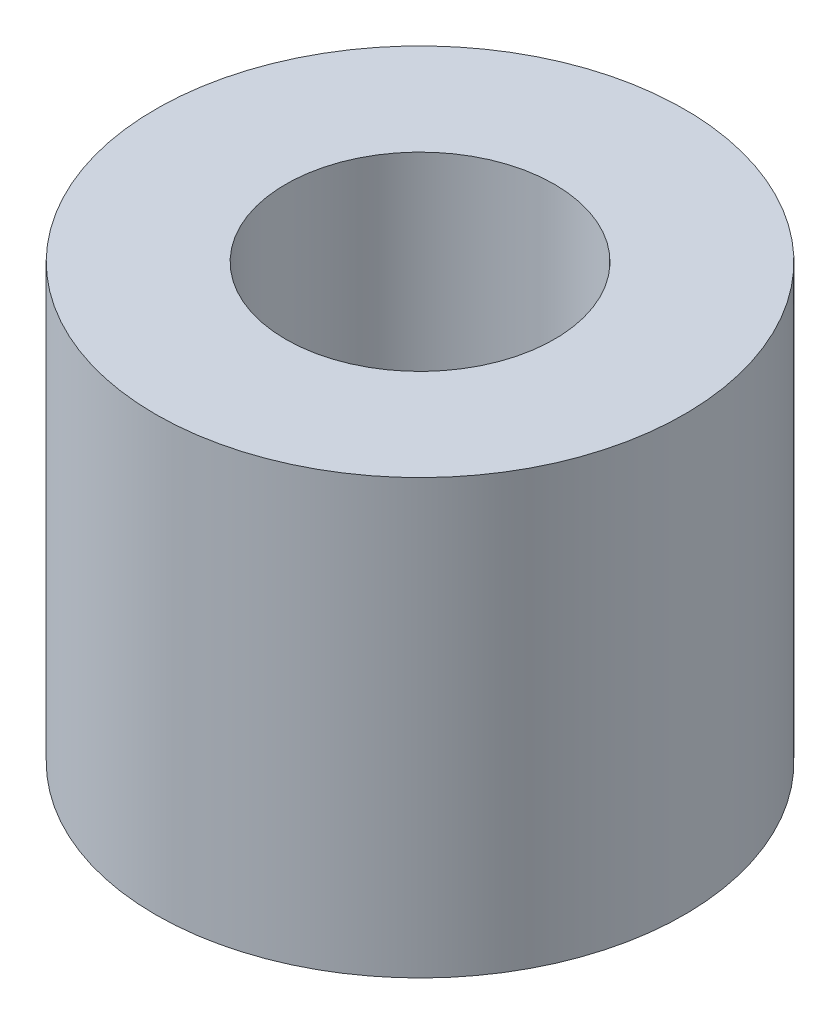
from build123d import *

# Parameters (mm, degrees)
SKETCH1_R           = 3.05
SKETCH1_R_2         = 1.55
BOSS_EXTRUDE1_DEPTH = 5


with BuildPart() as part:
    # Sketch1 → Boss-Extrude1 (new body)
    with BuildSketch(Plane(origin=(0, 0, 0), x_dir=(1, 0, 0), z_dir=(0, 1, 0))):
        Circle(SKETCH1_R)
        Circle(SKETCH1_R_2, mode=Mode.SUBTRACT)
    extrude(amount=BOSS_EXTRUDE1_DEPTH)


solid = part.part
